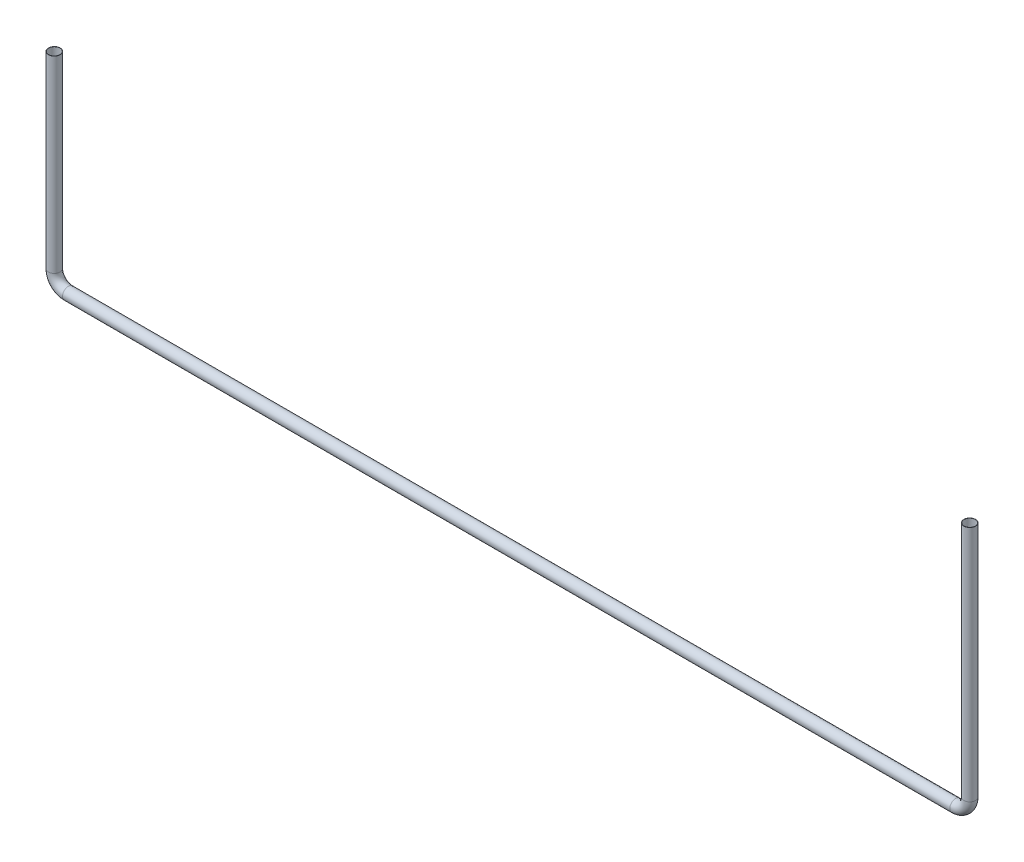
from build123d import *

# Parameters (mm, degrees)
SWEEP_THIN1_PROFILE_R   = 25
SWEEP_THIN1_PROFILE_R_2 = 24


with BuildPart() as part:
    # Sweep-Thin1: sweep along a curve in space
    with BuildLine() as sweep_thin1_path:
        Line((-38227.538989442, -16467.051351688, 42621.700196057), (-38227.538989442, -17268.463737534, 42621.700196057))
        ThreePointArc((-38167.538989442, -17328.463737534, 42621.700196057), (-38209.965396313, -17310.890144405, 42621.700196057), (-38227.538989442, -17268.463737534, 42621.700196057))
        Line((-38167.538989442, -17328.463737534, 42621.700196057), (-34389.400775884, -17328.463737534, 42621.700196057))
        ThreePointArc((-34389.400775884, -17328.463737534, 42621.700196057), (-34346.974369013, -17310.890144405, 42621.700196057), (-34329.400775884, -17268.463737534, 42621.700196057))
        Line((-34329.400775884, -17268.463737534, 42621.700196057), (-34329.400775884, -16256.626421741, 42621.700196057))
    # Sweep-Thin1 profile (on start of the path) → Sweep-Thin1 (sweep)
    with BuildSketch(Plane(origin=(-38227.538989442, -16467.051351688, 42621.700196057), x_dir=(0, 0, -1), z_dir=(0, -1, 0))):
        Circle(SWEEP_THIN1_PROFILE_R)
        Circle(SWEEP_THIN1_PROFILE_R_2, mode=Mode.SUBTRACT)
    sweep(path=sweep_thin1_path.line)


solid = part.part
